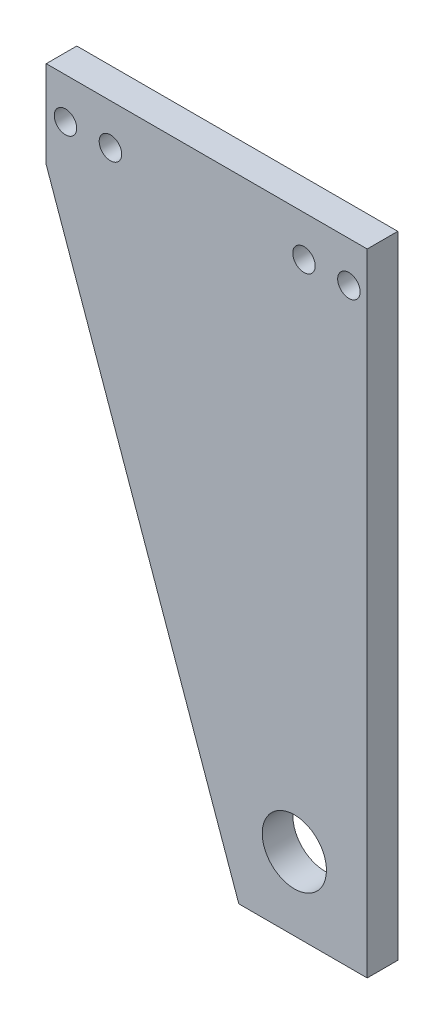
from build123d import *

# Parameters (mm, degrees)
CROQUIS1_R              = 1.75
CROQUIS1_R_2            = 5
SALIENTE_EXTRUIR1_DEPTH = 4.7625


with BuildPart() as part:
    # Croquis1 → Saliente-Extruir1 (new body)
    with BuildSketch(Plane.XY):
        Polygon((0, 0), (0, -98.35), (-20, -98.35), (-50, -13.632613432), (-50, 0), align=None)
        with Locations((-2.85, -6.35)):
            Circle(CROQUIS1_R, mode=Mode.SUBTRACT)
        with Locations((-9.85, -6.35)):
            Circle(CROQUIS1_R, mode=Mode.SUBTRACT)
        with Locations((-40, -6.35)):
            Circle(CROQUIS1_R, mode=Mode.SUBTRACT)
        with Locations((-47, -6.35)):
            Circle(CROQUIS1_R, mode=Mode.SUBTRACT)
        with Locations((-11.35, -87)):
            Circle(CROQUIS1_R_2, mode=Mode.SUBTRACT)
    extrude(amount=SALIENTE_EXTRUIR1_DEPTH)


solid = part.part
